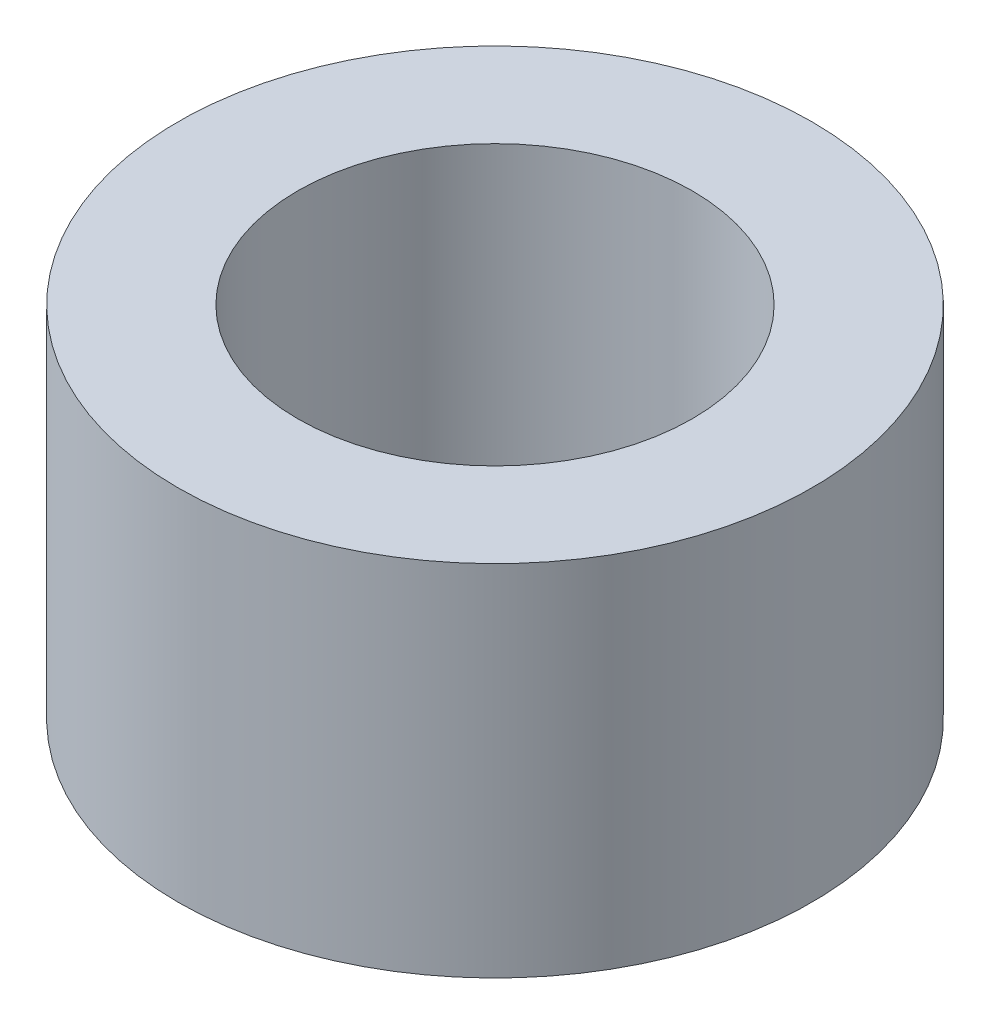
from build123d import *

# Parameters (mm, degrees)
SKETCH1_R           = 5.3
SKETCH1_R_2         = 3.3
BOSS_EXTRUDE1_DEPTH = 6


with BuildPart() as part:
    # Sketch1 → Boss-Extrude1 (new body)
    with BuildSketch(Plane(origin=(0, 0, 0), x_dir=(1, 0, 0), z_dir=(0, 1, 0))):
        Circle(SKETCH1_R)
        Circle(SKETCH1_R_2, mode=Mode.SUBTRACT)
    extrude(amount=BOSS_EXTRUDE1_DEPTH)


solid = part.part
